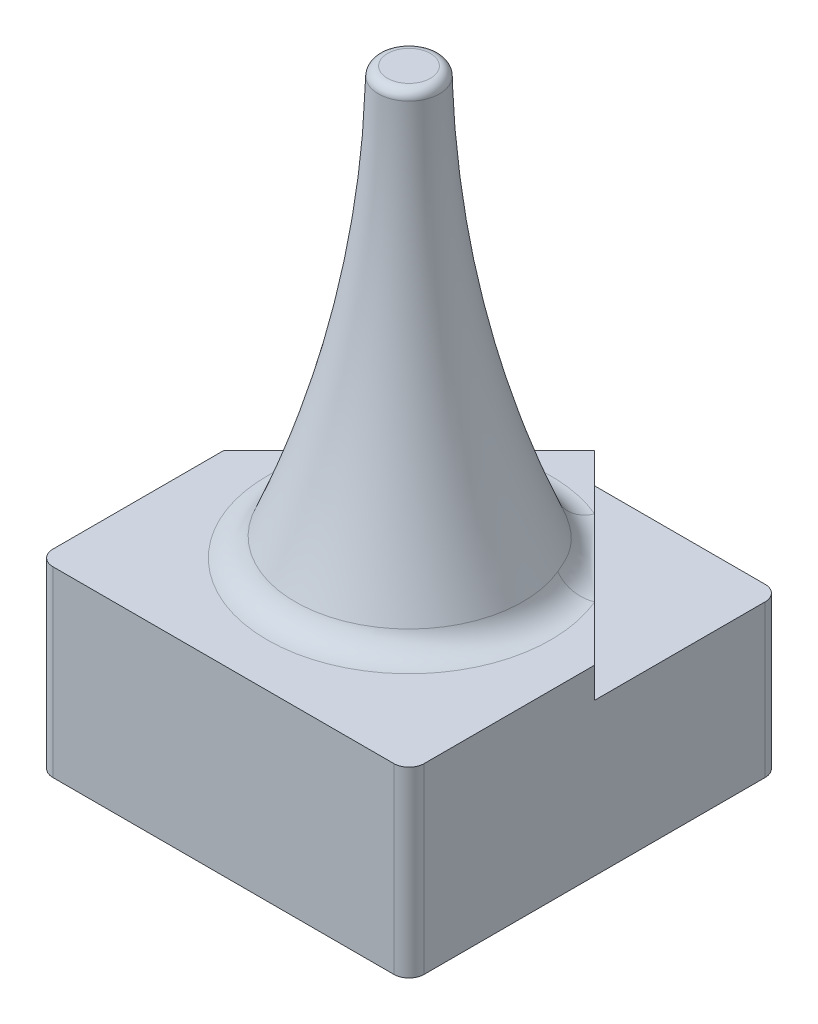
from build123d import *

# Parameters (mm, degrees)
ESQUISSE1_W             = 12.2
ESQUISSE1_H             = 12.2
BOSS_EXTRU_1_DEPTH      = 6
ENL_V_MAT_EXTRU_1_DEPTH = 1
CONG_2_R                = 0.3
CONG_3_R                = 0.5
CONG_4_R                = 1


with BuildPart() as part:
    # Esquisse1 → Boss.-Extru.1 (new body)
    with BuildSketch(Plane(origin=(0, 0, 0), x_dir=(1, 0, 0), z_dir=(0, 1, 0))):
        Rectangle(ESQUISSE1_W, ESQUISSE1_H)
    extrude(amount=BOSS_EXTRU_1_DEPTH)

    # Esquisse2 → Enlèv. mat.-Extru.1 (cut)
    with BuildSketch(Plane(origin=(0, 6, 0), x_dir=(1, 0, 0), z_dir=(0, 1, 0))):
        Polygon((-6.1, 6.1), (-6.1, 0), (0, 6.1), align=None)
        Polygon((6.1, 6.1), (0, 6.1), (6.1, 0), align=None)
    extrude(amount=-ENL_V_MAT_EXTRU_1_DEPTH, mode=Mode.SUBTRACT)

    # Esquisse4 → Révolution1 (revolve)
    with BuildSketch(Plane.XY):
        with BuildLine():
            Line((0, 20), (0, 6))
            Line((0, 6), (4, 6))
            add(Edge.make_bspline(
                [(4, 6), (1.118476113, 12.647093335), (1, 20)],
                knots=[0, 0, 0, 1, 1, 1], degree=2))
            Line((1, 20), (0, 20))
        make_face()
    revolve(axis=Axis((0, 20, 0), (0, -1, 0)))

    # Congé2
    cong_2_edges = [part.edges().sort_by_distance(p)[0] for p in [
        (-1, 20, 0),
    ]]
    fillet(cong_2_edges, radius=CONG_2_R)

    # Congé3
    cong_3_edges = [part.edges().sort_by_distance(p)[0] for p in [
        (-6.1, 2.5, -6.1),
        (6.1, 2.5, -6.1),
        (6.1, 3, 6.1),
        (-6.1, 3, 6.1),
    ]]
    fillet(cong_3_edges, radius=CONG_3_R)

    # Esquisse5 → Enlèvement de matière-Révolution1 (revolve, cut)
    with BuildSketch(Plane.XY):
        with BuildLine():
            Line((-0.15, 17), (-0.15, 0))
            Line((-0.15, 0), (4.472372581, 0))
            add(Edge.make_bspline(
                [(4.472372581, 0), (2.630008633, 3.831055764), (1.072108734, 14.115127784), (0.713133272, 17)],
                knots=[0, 0, 0, 0, 1, 1, 1, 1], degree=3))
            Line((0.713133272, 17), (-0.15, 17))
        make_face()
    revolve(axis=Axis((-0.15, 17, 0), (0, -1, 0)), mode=Mode.SUBTRACT)

    # Congé4
    cong_4_edges = [part.edges().sort_by_distance(p)[0] for p in [
        (-4, 6, 0),
    ]]
    fillet(cong_4_edges, radius=CONG_4_R)


solid = part.part
